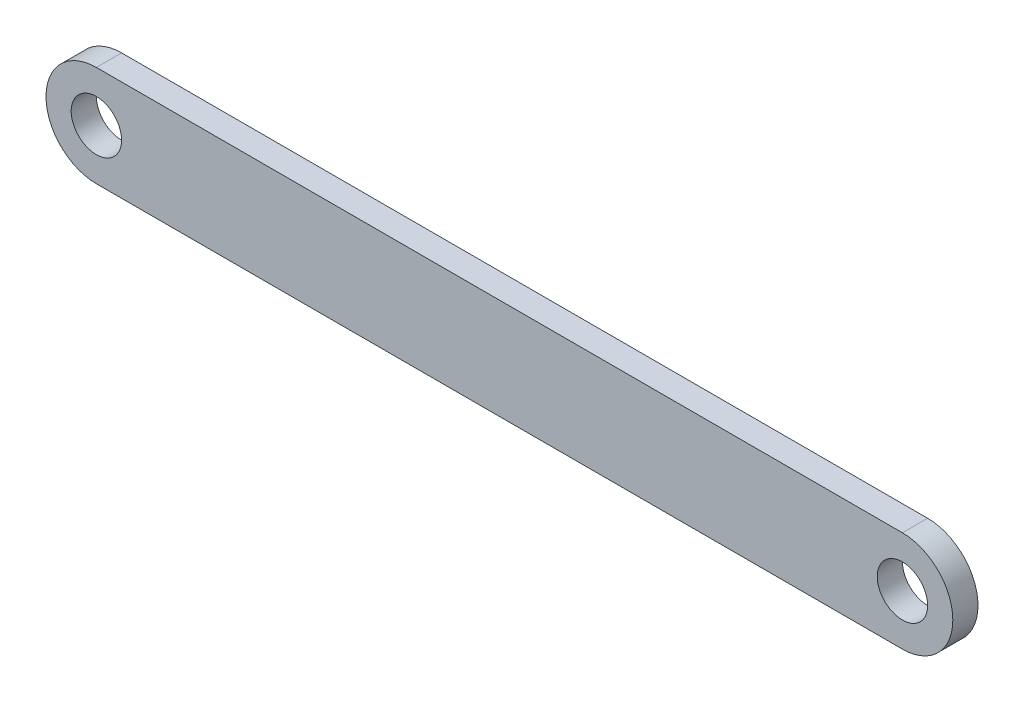
from build123d import *

# Parameters (mm, degrees)
EXTRUDE1_DEPTH     = 6.35
SKETCH5_R          = 6.35
CUT_EXTRUDE1_DEPTH = 7.35


with BuildPart() as part:
    # Sketch1 → Extrude1 (new body)
    with BuildSketch(Plane.XY):
        with BuildLine():
            Line((-101.6, 12.7), (101.6, 12.7))
            ThreePointArc((101.6, 12.7), (114.3, 0), (101.6, -12.7))
            Line((101.6, -12.7), (-101.6, -12.7))
            ThreePointArc((-101.6, -12.7), (-114.3, 0), (-101.6, 12.7))
        make_face()
    extrude(amount=EXTRUDE1_DEPTH)

    # Sketch5 → Cut-Extrude1 (cut, through all)
    with BuildSketch(Plane.XY.offset(6.35)):
        with Locations((-101.6, 0)):
            Circle(SKETCH5_R)
        with Locations((101.6, 0)):
            Circle(SKETCH5_R)
    extrude(amount=-CUT_EXTRUDE1_DEPTH, mode=Mode.SUBTRACT)


solid = part.part
